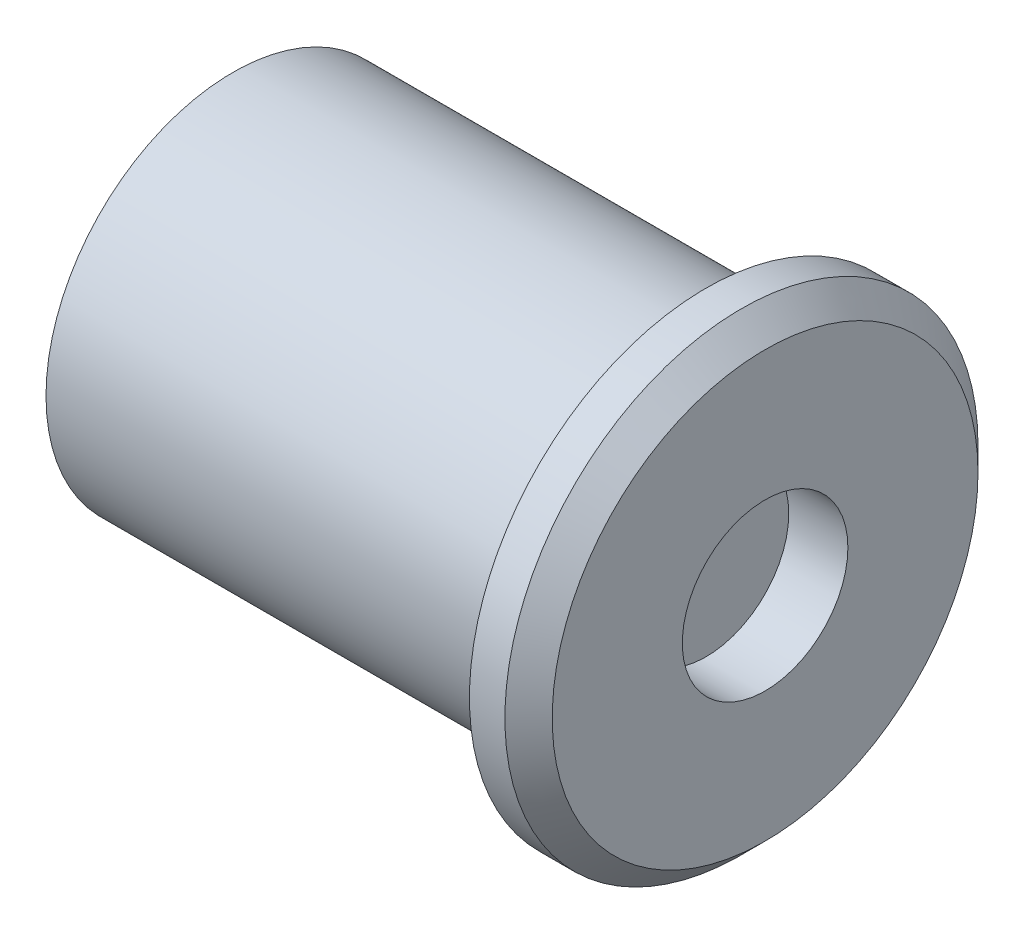
from build123d import *

# Parameters (mm, degrees)
SKETCH_1_R          = 7.9
EXTRUDE_1_DEPTH     = 20
SKETCH_6_R          = 10
EXTRUDE_2_DEPTH     = 2.5
SKETCH_7_R          = 3.5
CUT_EXTRUDE_3_DEPTH = 2.5
CHAMFER_1_SIZE      = 1


with BuildPart() as part:
    # 草图1 → 凸台-拉伸1 (new body)
    with BuildSketch(Plane(origin=(0, 0, 0), x_dir=(0, 0, -1), z_dir=(1, 0, 0))):
        Circle(SKETCH_1_R)
    extrude(amount=-EXTRUDE_1_DEPTH)

    # 草图6 → 凸台-拉伸2 (add)
    with BuildSketch(Plane(origin=(0, 0, 0), x_dir=(0, 0, -1), z_dir=(1, 0, 0))):
        Circle(SKETCH_6_R)
    extrude(amount=EXTRUDE_2_DEPTH)

    # 草图7 → 切除-拉伸3 (cut)
    with BuildSketch(Plane(origin=(2.5, 0, 0), x_dir=(0, 0, -1), z_dir=(1, 0, 0))):
        Circle(SKETCH_7_R)
    extrude(amount=-CUT_EXTRUDE_3_DEPTH, mode=Mode.SUBTRACT)

    # 倒角1
    chamfer_1_edges = [part.edges().sort_by_distance(p)[0] for p in [
        (2.5, 0, 10),
    ]]
    chamfer(chamfer_1_edges, length=CHAMFER_1_SIZE)


solid = part.part
